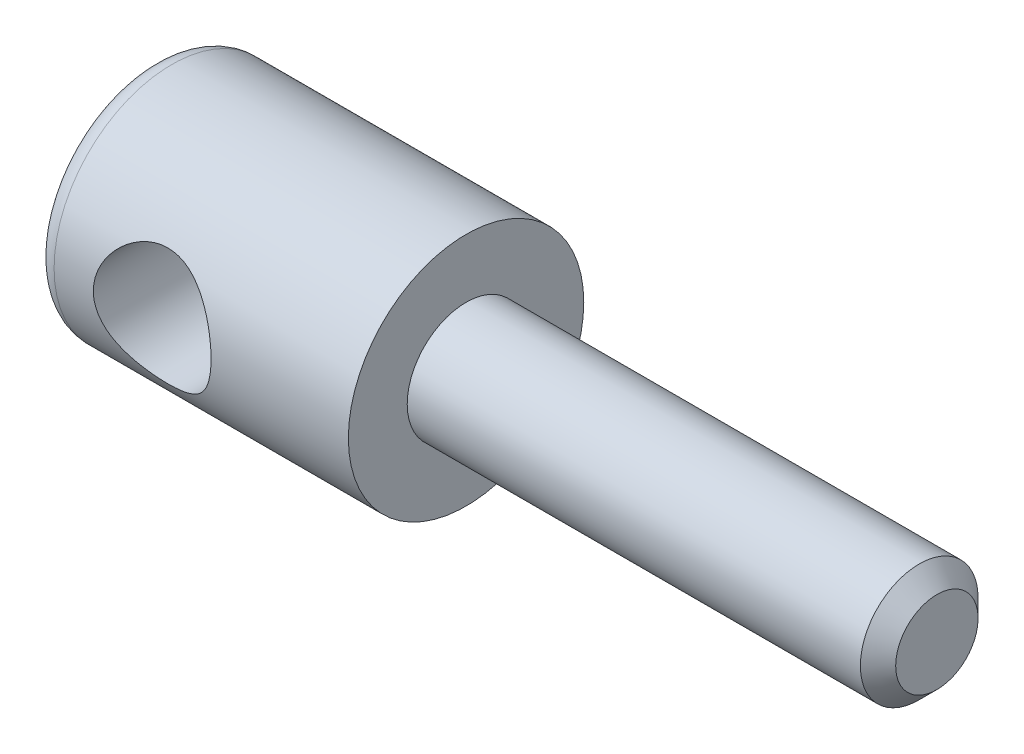
from build123d import *

# Parameters (mm, degrees)
F_3_8_0_3750_DOWEL_HOLE1_D = 9.525
FILLET2_R                  = 1.5875
CHAMFER3_SIZE              = 1.42875


with BuildPart() as part:
    # Sketch1 → Revolve1 (revolve)
    with BuildSketch(Plane.XY):
        Polygon((0, 0), (0, 9.525), (25.4, 9.525), (25.4, 4.7625), (63.5, 4.7625), (63.5, 0), align=None)
    revolve(axis=Axis((0, 0, 0), (1, 0, 0)))

    # 3/8 (0.3750) Dowel Hole1 (through all)
    with Locations(Plane.XY.offset(9.525)):
        with Locations((9.525, 0)):
            Hole(F_3_8_0_3750_DOWEL_HOLE1_D / 2)

    # Fillet2
    fillet2_edges = [part.edges().sort_by_distance(p)[0] for p in [
        (0, -9.525, 0),
    ]]
    fillet(fillet2_edges, radius=FILLET2_R)

    # Chamfer3
    chamfer3_edges = [part.edges().sort_by_distance(p)[0] for p in [
        (63.5, -4.7625, 0),
    ]]
    chamfer(chamfer3_edges, length=CHAMFER3_SIZE)


solid = part.part
